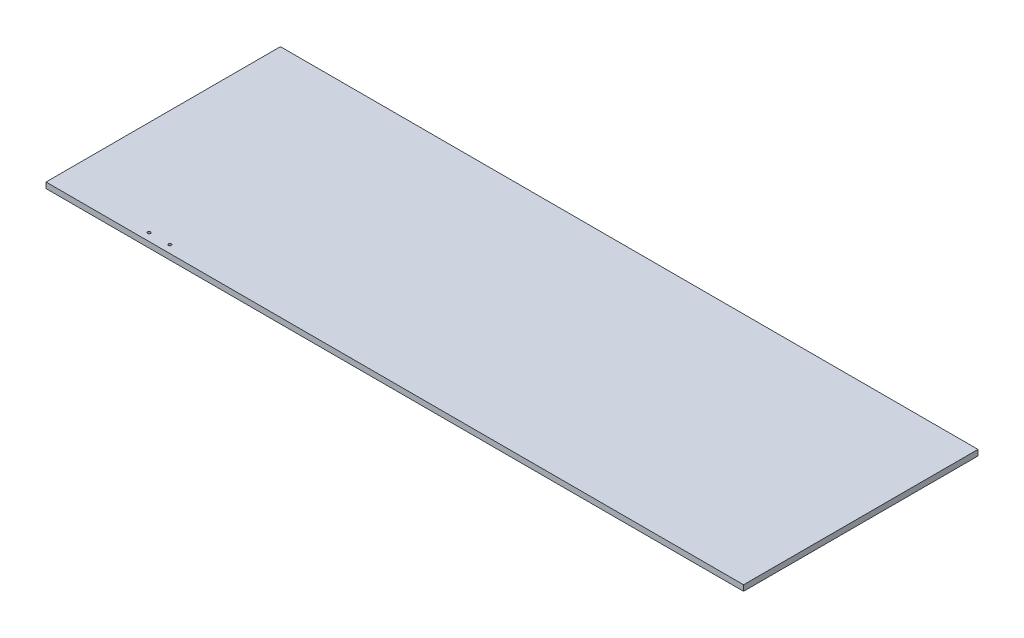
from build123d import *

# Parameters (mm, degrees)
SKETCH1_W           = 1220
SKETCH1_H           = 410
BOSS_EXTRUDE1_DEPTH = 10
SKETCH2_R           = 2.5
CUT_EXTRUDE1_DEPTH  = 10


with BuildPart() as part:
    # Sketch1 → Boss-Extrude1 (new body)
    with BuildSketch(Plane(origin=(0, 0, 0), x_dir=(1, 0, 0), z_dir=(0, 1, 0))):
        with Locations((610, 205)):
            Rectangle(SKETCH1_W, SKETCH1_H)
    extrude(amount=BOSS_EXTRUDE1_DEPTH)

    # Sketch2 → Cut-Extrude1 (cut)
    with BuildSketch(Plane(origin=(0, 0, 0), x_dir=(1, 0, 0), z_dir=(0, 1, 0))):
        with Locations((166.8, 13.5)):
            Circle(SKETCH2_R)
        with Locations((203.3, 13.5)):
            Circle(SKETCH2_R)
    extrude(amount=CUT_EXTRUDE1_DEPTH, mode=Mode.SUBTRACT)


solid = part.part
